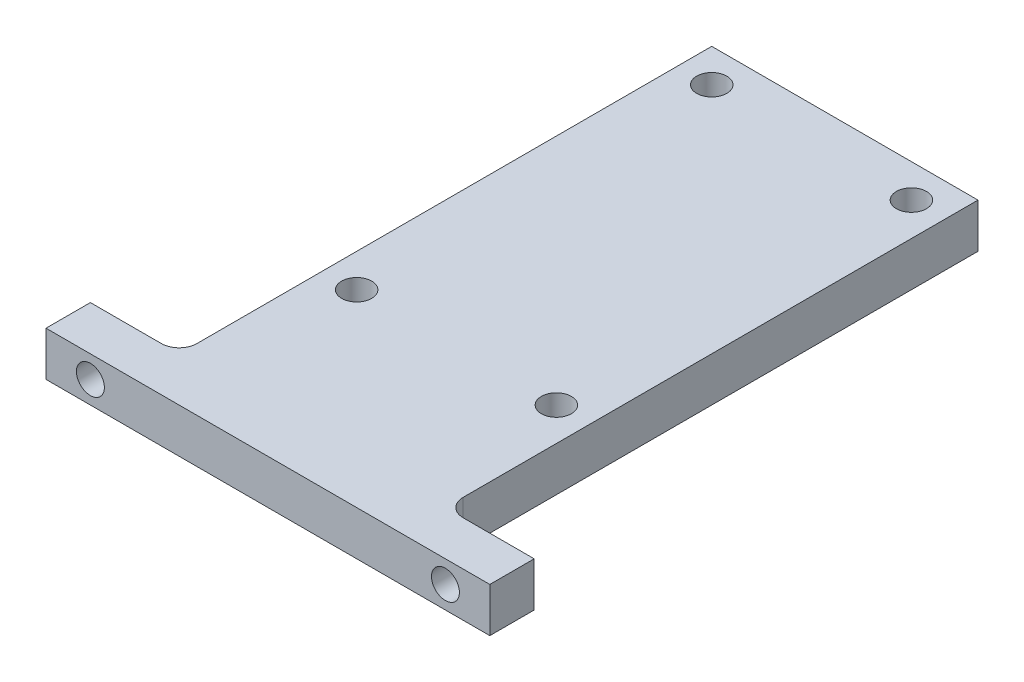
from build123d import *

# Parameters (mm, degrees)
BOSS_EXTRUDE1_DEPTH     = 6.35
SKETCH2_R               = 2
CUT_EXTRUDE1_DEPTH      = 1
CUT_EXTRUDE1_DEPTH_BACK = 83.55
FILLET1_R               = 2.54
M4_CLEARANCE_HOLE1_D    = 4.3


with BuildPart() as part:
    # Sketch1 → Boss-Extrude1 (new body)
    with BuildSketch(Plane(origin=(0, 0, 0), x_dir=(1, 0, 0), z_dir=(0, 1, 0))):
        Polygon((0, 0), (63.5, 0), (63.5, 6.35), (50.8, 6.35), (50.8, 82.55), (12.7, 82.55), (12.7, 6.35), (0, 6.35), align=None)
    extrude(amount=BOSS_EXTRUDE1_DEPTH)

    # Sketch2 → Cut-Extrude1 (cut, two sides)
    with BuildSketch(Plane.XY) as cut_extrude1_sk:
        with Locations((6.35, 3.175)):
            Circle(SKETCH2_R)
        with Locations((57.15, 3.175)):
            Circle(SKETCH2_R)
    extrude(amount=CUT_EXTRUDE1_DEPTH, mode=Mode.SUBTRACT)
    extrude(cut_extrude1_sk.sketch, amount=-CUT_EXTRUDE1_DEPTH_BACK, mode=Mode.SUBTRACT)

    # Fillet1
    fillet1_edges = [part.edges().sort_by_distance(p)[0] for p in [
        (12.7, 3.175, -6.35),
        (50.8, 3.175, -6.35),
    ]]
    fillet(fillet1_edges, radius=FILLET1_R)

    # M4 Clearance Hole1 (through all)
    with Locations(Plane(origin=(0, 6.35, 0), x_dir=(1, 0, 0), z_dir=(0, 1, 0))):
        with Locations((17.4625, 77.7875), (46.0375, 77.7875), (46.0375, 26.9875), (17.4625, 26.9875)):
            Hole(M4_CLEARANCE_HOLE1_D / 2)


solid = part.part
